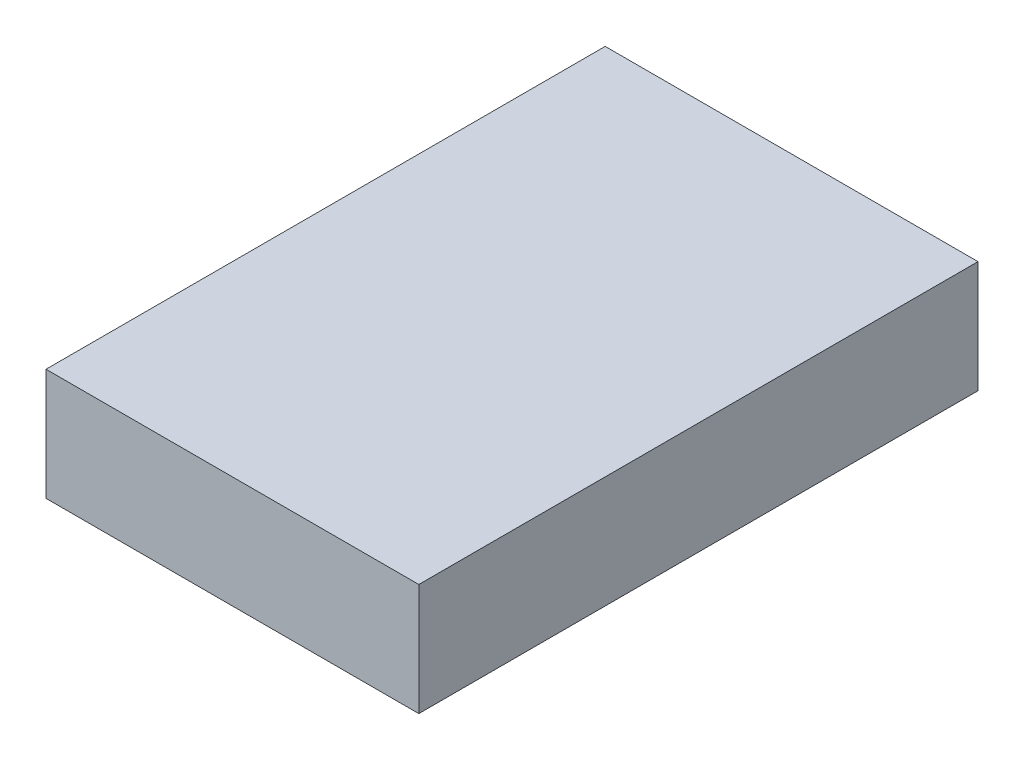
from build123d import *

# Parameters (mm, degrees)
SKETCH2_W           = 508
SKETCH2_H           = 762
BOSS_EXTRUDE1_DEPTH = 152.4


with BuildPart() as part:
    # Sketch2 → Boss-Extrude1 (new body)
    with BuildSketch(Plane(origin=(0, 0, 0), x_dir=(1, 0, 0), z_dir=(0, 1, 0))):
        Rectangle(SKETCH2_W, SKETCH2_H)
    extrude(amount=BOSS_EXTRUDE1_DEPTH)


solid = part.part
